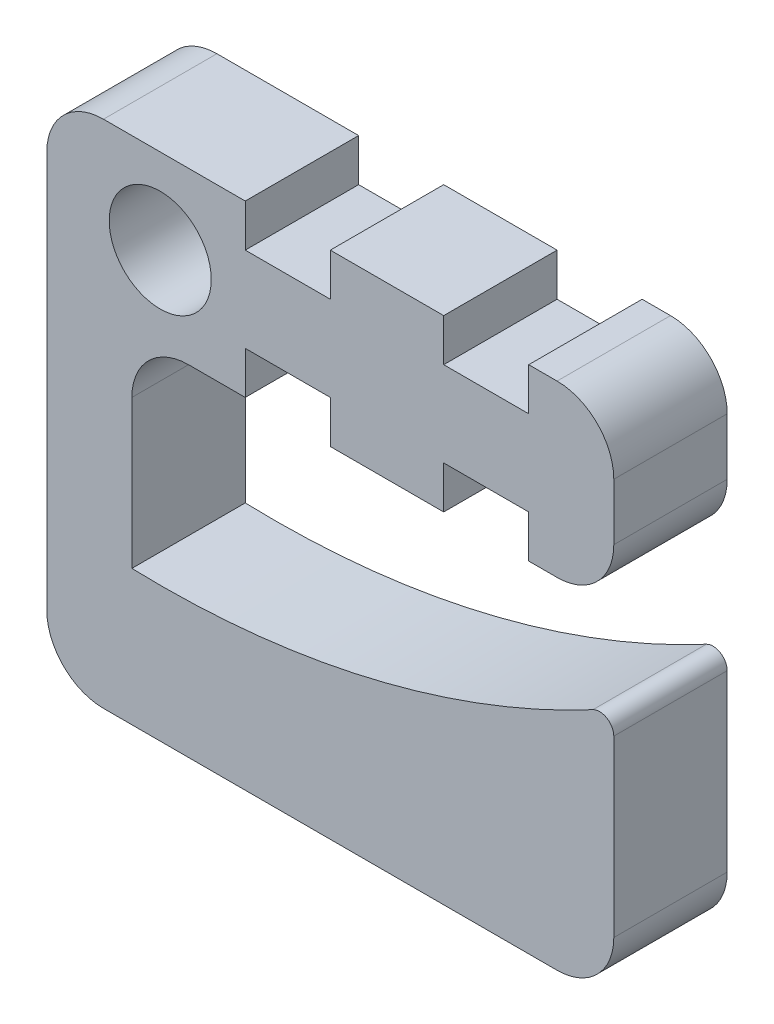
from build123d import *

# Parameters (mm, degrees)
SKETCH2_R           = 2.286
BOSS_EXTRUDE1_DEPTH = 5.08
FILLET1_R           = 2.54
FILLET2_R           = 0.635
SKETCH3_W           = 3.81
SKETCH3_H           = 1.905
CUT_EXTRUDE1_DEPTH  = 6.08


with BuildPart() as part:
    # Sketch2 → Boss-Extrude1 (new body)
    with BuildSketch(Plane.XY):
        with BuildLine():
            ThreePointArc((20.32, -7.62), (9.895271997, -11.792143987), (-1.27, -12.983127033))
            Line((-1.27, -12.983127033), (-1.27, -3.81))
            Line((-1.27, -3.81), (20.32, -3.81))
            Line((20.32, -3.81), (20.32, 3.81))
            Line((20.32, 3.81), (-5.08, 3.81))
            Line((-5.08, 3.81), (-5.08, -19.05))
            Line((-5.08, -19.05), (20.32, -19.05))
            Line((20.32, -19.05), (20.32, -7.62))
        make_face()
        Circle(SKETCH2_R, mode=Mode.SUBTRACT)
    extrude(amount=BOSS_EXTRUDE1_DEPTH)

    # Fillet1
    fillet1_edges = [part.edges().sort_by_distance(p)[0] for p in [
        (-5.08, 3.81, 2.54),
        (20.32, 3.81, 2.54),
        (20.32, -3.81, 2.54),
        (-1.27, -3.81, 2.54),
        (20.32, -19.05, 2.54),
        (-5.08, -19.05, 2.54),
    ]]
    fillet(fillet1_edges, radius=FILLET1_R)

    # Fillet2
    fillet2_edges = [part.edges().sort_by_distance(p)[0] for p in [
        (20.32, -7.62, 2.54),
    ]]
    fillet(fillet2_edges, radius=FILLET2_R)

    # Sketch3 → Cut-Extrude1 (cut, through all)
    with BuildSketch(Plane.XY.offset(5.08)):
        with Locations((5.715, 2.8575)):
            Rectangle(SKETCH3_W, SKETCH3_H)
        with Locations((5.715, -2.8575)):
            Rectangle(SKETCH3_W, SKETCH3_H)
        with Locations((14.605, 2.8575)):
            Rectangle(SKETCH3_W, SKETCH3_H)
        with Locations((14.605, -2.8575)):
            Rectangle(SKETCH3_W, SKETCH3_H)
    extrude(amount=-CUT_EXTRUDE1_DEPTH, mode=Mode.SUBTRACT)


solid = part.part
